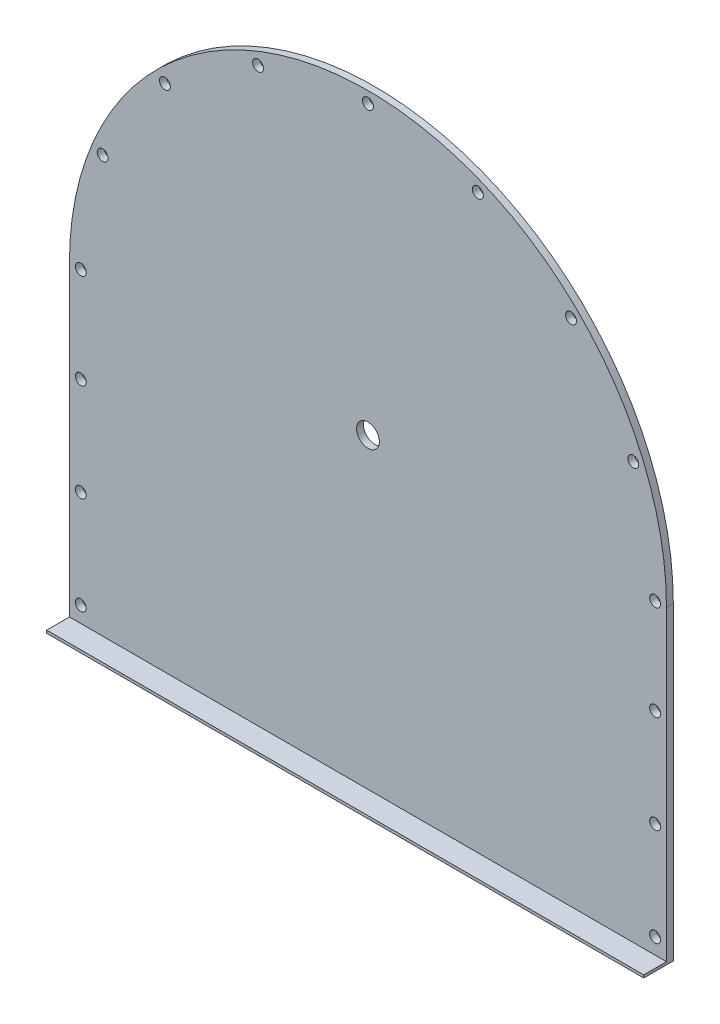
from build123d import *

# Parameters (mm, degrees)
BOSS_EXTRUDE1_DEPTH    = 15
BOTTOM_FLANGE_W        = 1312
BOTTOM_FLANGE_H        = 6
BOSS_EXTRUDE2_DEPTH    = 50
F_24_0MM_DOWEL_HOLE1_D = 24
CENTER_HOLE_R          = 25
CUT_EXTRUDE1_DEPTH     = 16


with BuildPart() as part:
    # base plate → Boss-Extrude1 (new body)
    with BuildSketch(Plane.XY):
        with BuildLine():
            Line((0, 0), (1312, 0))
            Line((1312, 0), (1312, 680))
            ThreePointArc((1312, 680), (656, 1336), (0, 680))
            Line((0, 680), (0, 0))
        make_face()
    extrude(amount=BOSS_EXTRUDE1_DEPTH)

    # bottom flange → Boss-Extrude2 (add)
    with BuildSketch(Plane.XY.offset(15)):
        with Locations((656, 3)):
            Rectangle(BOTTOM_FLANGE_W, BOTTOM_FLANGE_H)
    extrude(amount=BOSS_EXTRUDE2_DEPTH)

    # Ø24.0mm Dowel Hole1 (through all)
    with Locations(Plane.XY.offset(15)):
        with Locations((25, 680), (1287, 680), (25, 41), (25, 256), (25, 471), (1287, 41), (1287, 256), (1287, 471), (1238.967985015, 921.473245822), (1102.184378929, 1126.184378929), (897.473245822, 1262.967985015), (656, 1311), (414.526754178, 1262.967985015), (209.815621071, 1126.184378929), (73.032014985, 921.473245822)):
            Hole(F_24_0MM_DOWEL_HOLE1_D / 2)

    # center hole → Cut-Extrude1 (cut, through all)
    with BuildSketch(Plane.XY.offset(15)):
        with Locations((656, 680)):
            Circle(CENTER_HOLE_R)
    extrude(amount=-CUT_EXTRUDE1_DEPTH, mode=Mode.SUBTRACT)


solid = part.part
